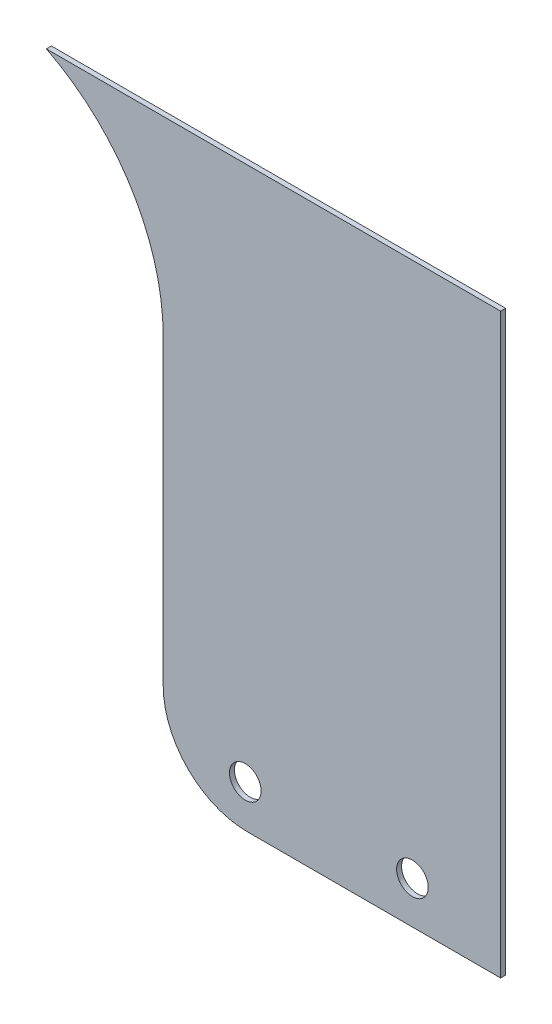
from build123d import *

# Parameters (mm, degrees)
SKETCH1_R      = 4.7625
EXTRUDE1_DEPTH = 1.5


with BuildPart() as part:
    # Sketch1 → Extrude1 (new body)
    with BuildSketch(Plane.XY.offset(165.1)):
        with BuildLine():
            Line((-418.175, 962.43), (-554.955743448, 962.43))
            ThreePointArc((-554.955743448, 962.43), (-529.269854117, 938.688748088), (-519.775, 905.024825288))
            Line((-519.775, 905.024825288), (-519.775, 813.93))
            ThreePointArc((-519.775, 813.93), (-512.335512242, 795.969487758), (-494.375, 788.53))
            Line((-494.375, 788.53), (-418.175, 788.53))
            Line((-418.175, 788.53), (-418.175, 962.43))
        make_face()
        with Locations((-444.7375, 801.23)):
            Circle(SKETCH1_R, mode=Mode.SUBTRACT)
        with Locations((-495.0625, 801.23)):
            Circle(SKETCH1_R, mode=Mode.SUBTRACT)
    extrude(amount=EXTRUDE1_DEPTH)


solid = part.part
